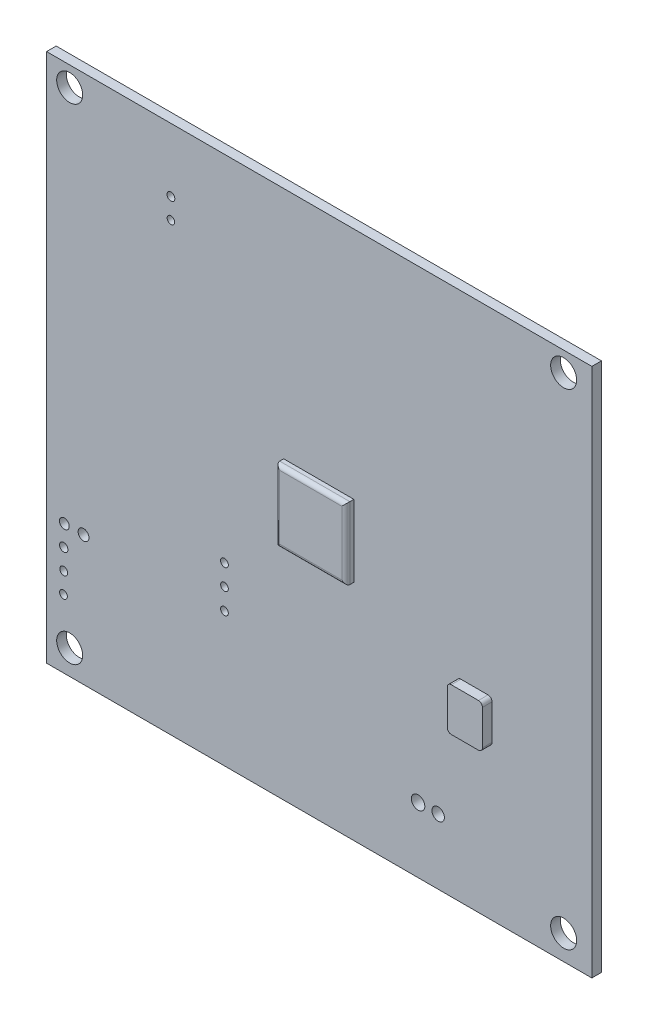
from build123d import *

# Parameters (mm, degrees)
ESQUISSE1_W        = 68.1
ESQUISSE1_H        = 66.15
ESQUISSE1_R        = 1.625
ESQUISSE1_R_2      = 0.5199497
ESQUISSE1_R_3      = 0.496597476
ESQUISSE1_R_4      = 0.485049202
ESQUISSE1_R_5      = 0.608998307
ESQUISSE1_R_6      = 0.677903493
ESQUISSE1_R_7      = 0.838572367
ESQUISSE1_R_8      = 0.778774178
ESQUISSE1_R_9      = 0.487785526
ESQUISSE1_R_10     = 0.479472078
ESQUISSE1_R_11     = 0.483052504
ESQUISSE1_R_12     = 0.489527541
ESQUISSE1_R_13     = 0.470271612
BOSS_EXTRU_1_DEPTH = 1.2
ESQUISSE3_W        = 8.757871462
ESQUISSE3_H        = 8.976039079
BOSS_EXTRU_2_DEPTH = 1
CONG_1_R           = 0.5
ESQUISSE4_W        = 4.395615229
ESQUISSE4_H        = 5.378660169
BOSS_EXTRU_3_DEPTH = 1.2
CONG_2_R           = 0.5


with BuildPart() as part:
    # Esquisse1 → Boss.-Extru.1 (new body)
    with BuildSketch(Plane.XY):
        with Locations((52.364343219, 246.888419198)):
            Rectangle(ESQUISSE1_W, ESQUISSE1_H)
        with Locations((21.20400612, 216.902097721)):
            Circle(ESQUISSE1_R, mode=Mode.SUBTRACT)
        with Locations((82.892966431, 216.902097721)):
            Circle(ESQUISSE1_R, mode=Mode.SUBTRACT)
        with Locations((21.20400612, 277.517138812)):
            Circle(ESQUISSE1_R, mode=Mode.SUBTRACT)
        with Locations((82.892966431, 277.517138812)):
            Circle(ESQUISSE1_R, mode=Mode.SUBTRACT)
        with Locations((20.460946771, 227.424751553)):
            Circle(ESQUISSE1_R_2, mode=Mode.SUBTRACT)
        with Locations((20.460946771, 224.857942008)):
            Circle(ESQUISSE1_R_3, mode=Mode.SUBTRACT)
        with Locations((20.428852881, 222.304104047)):
            Circle(ESQUISSE1_R_4, mode=Mode.SUBTRACT)
        with Locations((20.539364867, 230.017790559)):
            Circle(ESQUISSE1_R_5, mode=Mode.SUBTRACT)
        with Locations((22.937900475, 230.017790559)):
            Circle(ESQUISSE1_R_6, mode=Mode.SUBTRACT)
        with Locations((64.715000433, 221.952763309)):
            Circle(ESQUISSE1_R_7, mode=Mode.SUBTRACT)
        with Locations((67.21953945, 221.952763309)):
            Circle(ESQUISSE1_R_8, mode=Mode.SUBTRACT)
        with Locations((40.53207734, 235.781211634)):
            Circle(ESQUISSE1_R_9, mode=Mode.SUBTRACT)
        with Locations((40.53207734, 233.196854691)):
            Circle(ESQUISSE1_R_10, mode=Mode.SUBTRACT)
        with Locations((40.53207734, 230.561657941)):
            Circle(ESQUISSE1_R_11, mode=Mode.SUBTRACT)
        with Locations((33.847033777, 272.050619819)):
            Circle(ESQUISSE1_R_12, mode=Mode.SUBTRACT)
        with Locations((33.847033777, 269.501928251)):
            Circle(ESQUISSE1_R_13, mode=Mode.SUBTRACT)
    extrude(amount=-BOSS_EXTRU_1_DEPTH)

    # Esquisse3 → Boss.-Extru.2 (add)
    with BuildSketch(Plane.XY):
        with Locations((52.308376614, 246.236021207)):
            Rectangle(ESQUISSE3_W, ESQUISSE3_H)
    extrude(amount=BOSS_EXTRU_2_DEPTH)

    # Congé1
    cong_1_edges = [part.edges().sort_by_distance(p)[0] for p in [
        (47.929440883, 246.236021207, 1),
        (52.308376614, 241.748001667, 1),
        (56.687312345, 246.236021207, 1),
        (52.308376614, 250.724040746, 1),
    ]]
    fillet(cong_1_edges, radius=CONG_1_R)

    # Esquisse4 → Boss.-Extru.3 (add)
    with BuildSketch(Plane.XY):
        with Locations((71.755113955, 235.261974176)):
            Rectangle(ESQUISSE4_W, ESQUISSE4_H)
    extrude(amount=BOSS_EXTRU_3_DEPTH)

    # Congé2
    cong_2_edges = [part.edges().sort_by_distance(p)[0] for p in [
        (69.55730634, 237.95130426, 0.6),
        (69.55730634, 232.572644091, 0.6),
        (73.952921569, 232.572644091, 0.6),
        (73.952921569, 237.95130426, 0.6),
    ]]
    fillet(cong_2_edges, radius=CONG_2_R)


solid = part.part
